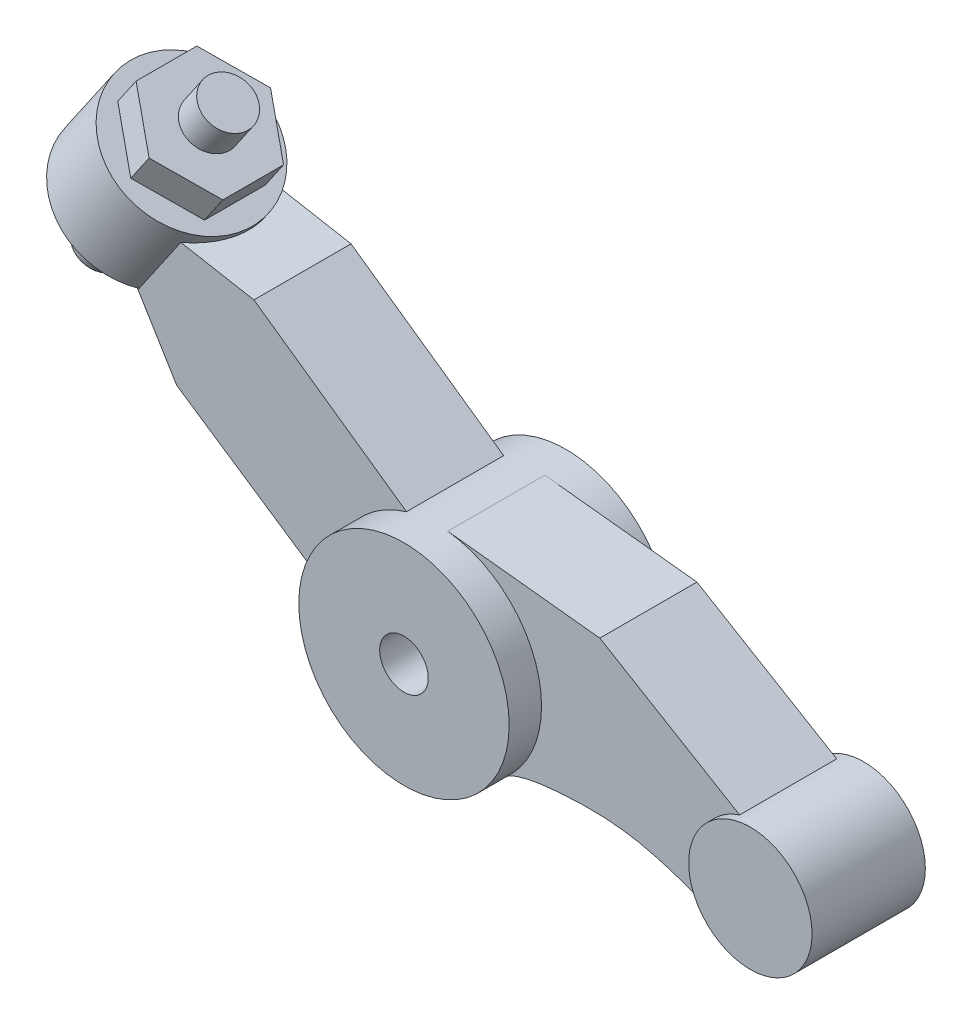
from build123d import *

# Parameters (mm, degrees)
SKETCH1_R           = 0.3
BOSS_EXTRUDE1_DEPTH = 1
BOSS_EXTRUDE2_DEPTH = 0.7
BOSS_EXTRUDE3_DEPTH = 0.6
BOSS_EXTRUDE4_DEPTH = 0.6
BOSS_EXTRUDE5_DEPTH = 0.4
SKETCH5_R           = 0.3
BOSS_EXTRUDE6_DEPTH = 0.4


with BuildPart() as part:
    # Sketch1 → Boss-Extrude1 (new, symmetric)
    with BuildSketch(Plane.XY):
        with BuildLine():
            ThreePointArc((1.3, 0), (0.967631362, 0.868152951), (0.140477621, 1.292387727))
            ThreePointArc((0.140477621, 1.292387727), (-0.11642585, 1.294776051), (-0.368782161, 1.24659525))
            ThreePointArc((-0.368782161, 1.24659525), (-1.071749439, 0.735767042), (-1.295848634, -0.103809043))
            ThreePointArc((-1.295848634, -0.103809043), (-0.48915419, -1.204461779), (0.856533864, -0.977931357))
            ThreePointArc((0.856533864, -0.977931357), (1.183953974, -0.536891971), (1.3, 0))
        make_face()
        Circle(SKETCH1_R, mode=Mode.SUBTRACT)
    extrude(amount=BOSS_EXTRUDE1_DEPTH, both=True)



with BuildPart() as body_2:
    # Sketch1_3 → Boss-Extrude2 (new, symmetric)
    with BuildSketch(Plane.XY):
        with BuildLine():
            ThreePointArc((4.7425, -0.66624549), (4.429408871, -0.050260168), (3.747253005, 0.059864065))
            ThreePointArc((3.747253005, 0.059864065), (3.252423356, -0.438126053), (3.374350994, -1.12949006))
            ThreePointArc((3.374350994, -1.12949006), (4.224539243, -1.388469007), (4.7425, -0.66624549))
        make_face()
    extrude(amount=BOSS_EXTRUDE2_DEPTH, both=True)


with BuildPart() as part_1:
    add(part.part)

    add(body_2.part)  # Boss-Extrude3 merges body 2
    # Sketch1_4 → Boss-Extrude3 (add, symmetric)
    with BuildSketch(Plane.XY):
        with BuildLine():
            ThreePointArc((3.374350994, -1.12949006), (3.252423356, -0.438126053), (3.747253005, 0.059864065))
            Line((3.747253005, 0.059864065), (2.019976925, 1.088093316))
            Line((2.019976925, 1.088093316), (0.140477621, 1.292387727))
            ThreePointArc((0.140477621, 1.292387727), (0.967631362, 0.868152951), (1.3, 0))
            ThreePointArc((1.3, 0), (1.183953974, -0.536891971), (0.856533864, -0.977931357))
            add(Edge.make_bspline(
                [(3.374350994, -1.12949006), (2.778476345, -0.90659845), (2.406966993, -0.786012749), (1.50197992, -0.807474496), (0.996483155, -0.855354956), (0.856533864, -0.977931357)],
                knots=[0, 0, 0, 0, 0.647248286, 0.718239717, 1, 1, 1, 1], degree=3))
        make_face()
    extrude(amount=BOSS_EXTRUDE3_DEPTH, both=True)

    # Sketch1_5 → Boss-Extrude4 (add, symmetric)
    with BuildSketch(Plane.XY):
        with BuildLine():
            ThreePointArc((-1.295848634, -0.103809043), (-1.071749439, 0.735767042), (-0.368782161, 1.24659525))
            Line((-0.368782161, 1.24659525), (-2.254212966, 2.57050074))
            Line((-2.254212966, 2.57050074), (-3.469420101, 2.791170079))
            Line((-3.469420101, 2.791170079), (-3.851452989, 2.234684794))
            Line((-3.851452989, 2.234684794), (-3.20884425, 1.179944376))
            Line((-3.20884425, 1.179944376), (-1.295848634, -0.103809043))
        make_face()
    extrude(amount=BOSS_EXTRUDE4_DEPTH, both=True)



with BuildPart() as body_2_2:
    # Sketch2 → Revolve1 (revolve)
    with BuildSketch(Plane.XY):
        with BuildLine():
            Line((-3.851452989, 2.234684794), (-3.357165564, 2.954684794))
            Line((-3.357165564, 2.954684794), (-3.682812508, 3.17824478))
            Line((-3.682812508, 3.17824478), (-4.833144721, 1.502622153))
            ThreePointArc((-4.833144721, 1.502622153), (-4.406042562, 1.526493017), (-4.321028806, 1.945728909))
            Line((-4.321028806, 1.945728909), (-3.851452989, 2.234684794))
        make_face()
    revolve(axis=Axis((-3.682812508, 3.17824478, 0), (-0.5659746478395022, -0.8244226452511791, 0)))


with BuildPart() as part_2:
    add(part_1.part)

    add(body_2_2.part)  # Revolve2 merges body 2 2
    # Sketch3 → Revolve2 (revolve)
    with BuildSketch(Plane.XY):
        Polygon((-3.62534147, 3.261959529), (-4.236594089, 2.371583072), (-4.986818697, 2.886620001), (-4.375566077, 3.776996458), align=None)
    revolve(axis=Axis((-3.62534147, 3.261959529, 0), (-0.5659746478394974, -0.8244226452511825, 0)))

    # Sketch4 → Boss-Extrude5 (add)
    with BuildSketch(Plane(origin=(0.36074202, 0.525472106, 0), x_dir=(0.8244226452511824, -0.5659746478394974, 0), z_dir=(0.5659746478394974, 0.8244226452511824, 0))):
        Polygon((-4.835, -0.75055535), (-4.185, -0.375277675), (-4.185, 0.375277675), (-4.835, 0.75055535), (-5.485, 0.375277675), (-5.485, -0.375277675), align=None)
    extrude(amount=BOSS_EXTRUDE5_DEPTH)

    # Sketch5 → Boss-Extrude6 (add)
    with BuildSketch(Plane(origin=(0.587131879, 0.855241165, 0), x_dir=(0.8244226452511826, -0.5659746478394971, 0), z_dir=(0.5659746478394971, 0.8244226452511827, 0))):
        with Locations((-4.835, 0)):
            Circle(SKETCH5_R)
    extrude(amount=BOSS_EXTRUDE6_DEPTH)


solid = part_2.part
